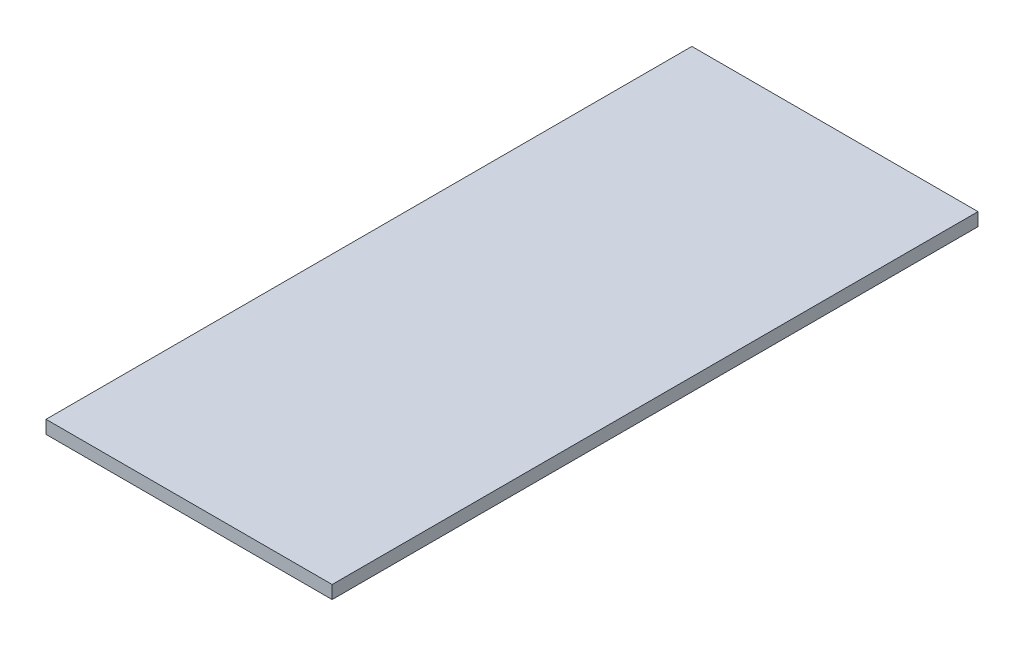
from build123d import *

# Parameters (mm, degrees)
SKETCH_1_W      = 17.5
SKETCH_1_H      = 39.5
EXTRUDE_1_DEPTH = 0.8


with BuildPart() as part:
    # 草图1 → 凸台-拉伸1 (new body)
    with BuildSketch(Plane(origin=(0, 4.029451354, 0), x_dir=(1, 0, 0), z_dir=(0, 1, 0))):
        with Locations((-6.5, -51.113349465)):
            Rectangle(SKETCH_1_W, SKETCH_1_H)
    extrude(amount=EXTRUDE_1_DEPTH)


solid = part.part
